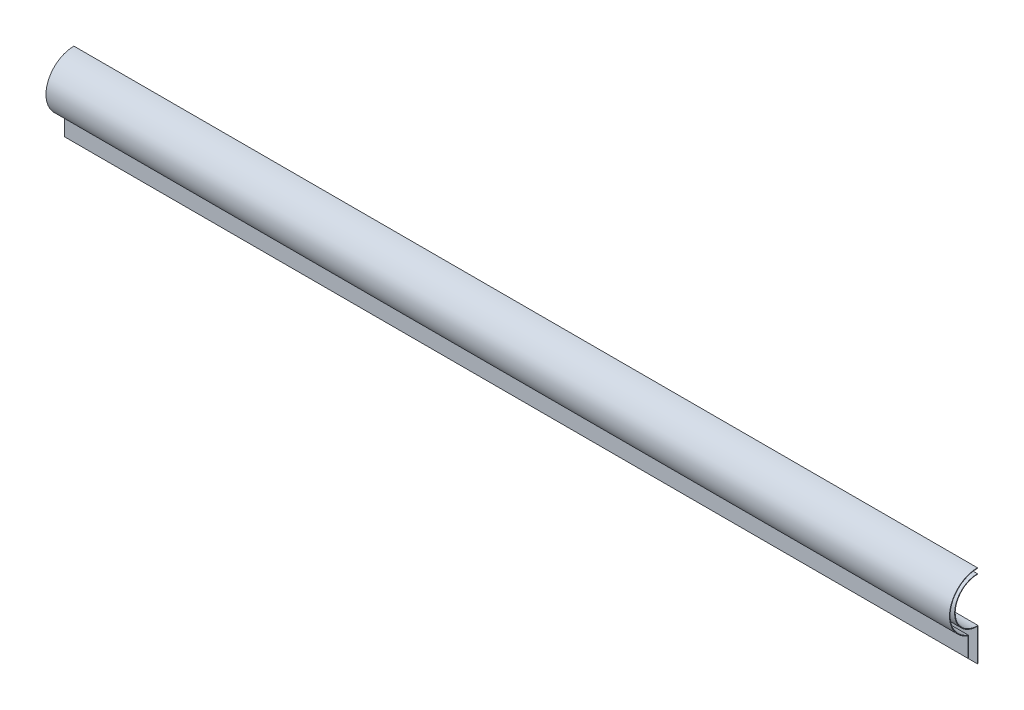
from build123d import *

# Parameters (mm, degrees)
DODANIE_WYCI_GNI_CIE1_DEPTH = 495
SKORUPA1_T                  = 0.3
SZKIC2_W                    = 0.537419475
SZKIC2_H                    = 5.433036789
WYTNIJ_WYCI_GNI_CIE1_DEPTH  = 930.783201162
WYTNIJ_WYCI_GNI_CIE2_DEPTH  = 930.783201162


with BuildPart() as part:
    # Szkic1 → Dodanie-wyciągnięcie1 (new body)
    with BuildSketch(Plane(origin=(-26.202987023, 0, 0), x_dir=(0, 0, -1), z_dir=(1, 0, 0))):
        with BuildLine():
            Line((-237.681641948, 742.5), (-237.681641948, 745))
            ThreePointArc((-237.681641948, 745), (-252.465620342, 732.536529681), (-242.681641948, 715.857864376))
            Line((-242.681641948, 715.857864376), (-242.681641948, 705))
            Line((-242.681641948, 705), (-237.681641948, 700))
            Line((-237.681641948, 700), (-237.681641948, 717.5))
            ThreePointArc((-237.681641948, 717.5), (-250.181641948, 730), (-237.681641948, 742.5))
        make_face()
    extrude(amount=-DODANIE_WYCI_GNI_CIE1_DEPTH)

    # Skorupa1
    skorupa1_openings = [part.faces().sort_by_distance(p)[0] for p in [
        (-26.202987023, 743.75, 238.155983597),
        (-521.202987023, 743.75, 238.155983597),
    ]]
    offset(amount=SKORUPA1_T, openings=skorupa1_openings, kind=Kind.INTERSECTION)

    # Szkic2 → Wytnij-wyciągnięcie1 (cut, through all)
    with BuildSketch(Plane.ZY.offset(521.202987023)):
        Polygon((242.681641948, 705), (237.681641948, 705), (237.681641948, 695.383160832), (244.897619128, 695.383160832), (244.897619128, 705), align=None)
        with Locations((237.412932211, 743.996017968)):
            Rectangle(SZKIC2_W, SZKIC2_H)
    extrude(amount=-WYTNIJ_WYCI_GNI_CIE1_DEPTH, mode=Mode.SUBTRACT)


with BuildPart() as wytnij_wyci_gni_cie1_piece_1:
    # of the separate pieces the step leaves, piece 1, a body of its own (wytnij_wyci_gni_cie1_pieces)
    add(part.part.solids().sort_by_distance((-26.202987023, 717.5, 237.681641948))[0])

    # Szkic3 → Wytnij-wyciągnięcie2 (cut, through all)
    with BuildSketch(Plane(origin=(-26.202987023, 0, 0), x_dir=(0, 0, -1), z_dir=(1, 0, 0))):
        Polygon((-237.681641948, 699.7), (-237.13154062, 699.7), (-237.13154062, 698.976022056), (-237.977292852, 698.976022056), align=None)
    extrude(amount=-WYTNIJ_WYCI_GNI_CIE2_DEPTH, mode=Mode.SUBTRACT)


with BuildPart() as wytnij_wyci_gni_cie1_piece_2:
    # of the separate pieces the step leaves, piece 2, a body of its own (wytnij_wyci_gni_cie1_pieces)
    add(part.part.solids().sort_by_distance((-26.202987023, 745, 237.681641948))[0])


solid = Compound([wytnij_wyci_gni_cie1_piece_1.part, wytnij_wyci_gni_cie1_piece_2.part])
